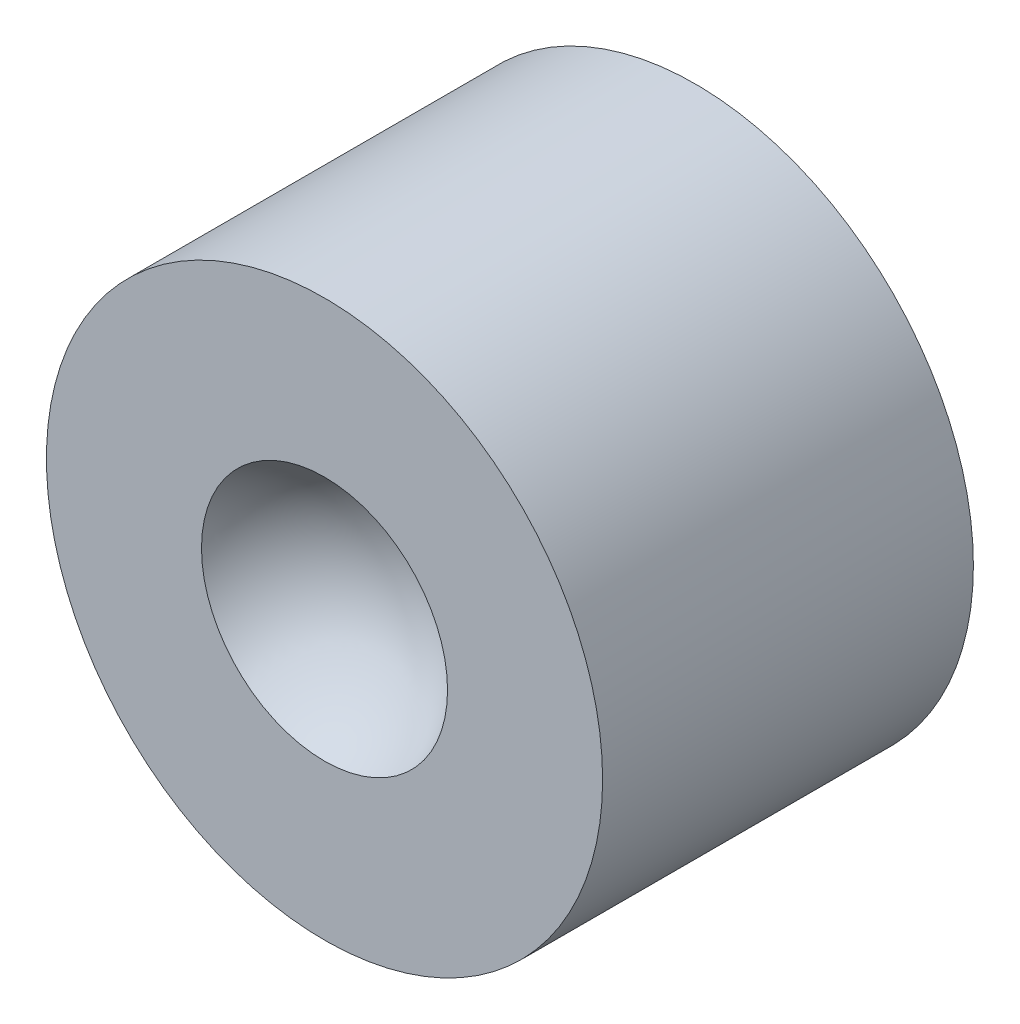
from build123d import *

# Parameters (mm, degrees)
SKETCH1_R           = 4.7625
BOSS_EXTRUDE1_DEPTH = 6.35


with BuildPart() as part:
    # Sketch1 → Boss-Extrude1 (new body)
    with BuildSketch(Plane.XY):
        Circle(SKETCH1_R)
    extrude(amount=BOSS_EXTRUDE1_DEPTH)

    # Sketch3 → Cut-Revolve1 (revolve, cut)
    with BuildSketch(Plane(origin=(0, 0, 0), x_dir=(1, 0, 0), z_dir=(0, 1, 0))):
        with BuildLine():
            Line((0, -6.35), (0, -5.08))
            ThreePointArc((0, -5.08), (1.230171572, -5.421843797), (2.10693, -6.35))
            Line((2.10693, -6.35), (0, -6.35))
        make_face()
    revolve(axis=Axis((0, 0, 0), (0, 0, 1)), mode=Mode.SUBTRACT)


solid = part.part
